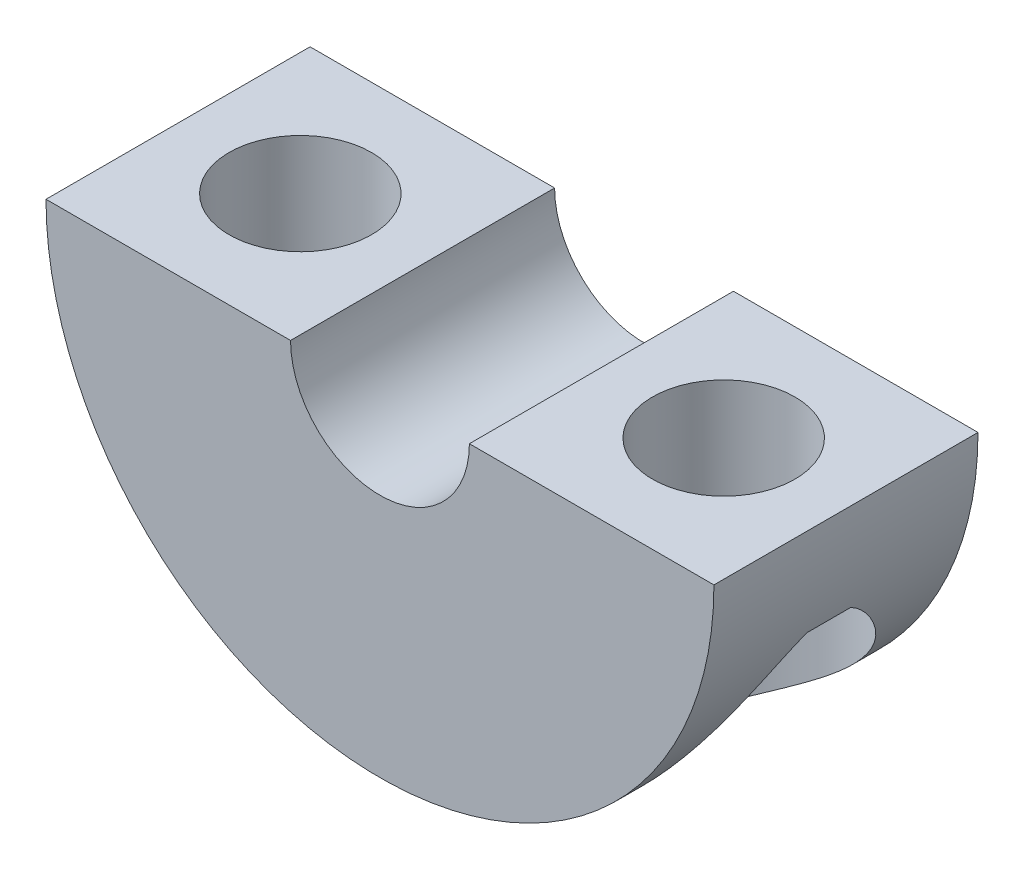
from build123d import *

# Parameters (mm, degrees)
BOSS_EXTRUDE1_DEPTH      = 6
BOSS_EXTRUDE1_DEPTH_BACK = 6


with BuildPart() as part:
    # Sketch1 → Boss-Extrude1 (new body, two sides)
    with BuildSketch(Plane.XY) as boss_extrude1_sk:
        with BuildLine():
            Line((15.1765, 0), (4.064, 0))
            ThreePointArc((4.064, 0), (0, -4.064), (-4.064, 0))
            Line((-4.064, 0), (-15.1765, 0))
            ThreePointArc((-15.1765, 0), (0, -15.1765), (15.1765, 0))
        make_face()
    extrude(amount=BOSS_EXTRUDE1_DEPTH)
    extrude(boss_extrude1_sk.sketch, amount=-BOSS_EXTRUDE1_DEPTH_BACK)

    # Sketch2 → Cut-Revolve1 (revolve, cut)
    with BuildSketch(Plane.XY):
        Polygon((-9.62025, 0), (-6.38175, 0), (-6.38175, -4.7625), (-4.73075, -4.7625), (-4.73075, -14.4203383), (-9.62025, -14.4203383), align=None)
    cut_revolve1 = revolve(axis=Axis((-9.62025, -14.4203383, 0), (0, 1, 0)), mode=Mode.SUBTRACT)

    # Mirror1: Cut-Revolve1 across plane
    add(cut_revolve1.mirror(Plane(origin=(0, 0, 0), x_dir=(0, 0, 1), z_dir=(1, 0, 0))), mode=Mode.SUBTRACT)


solid = part.part
